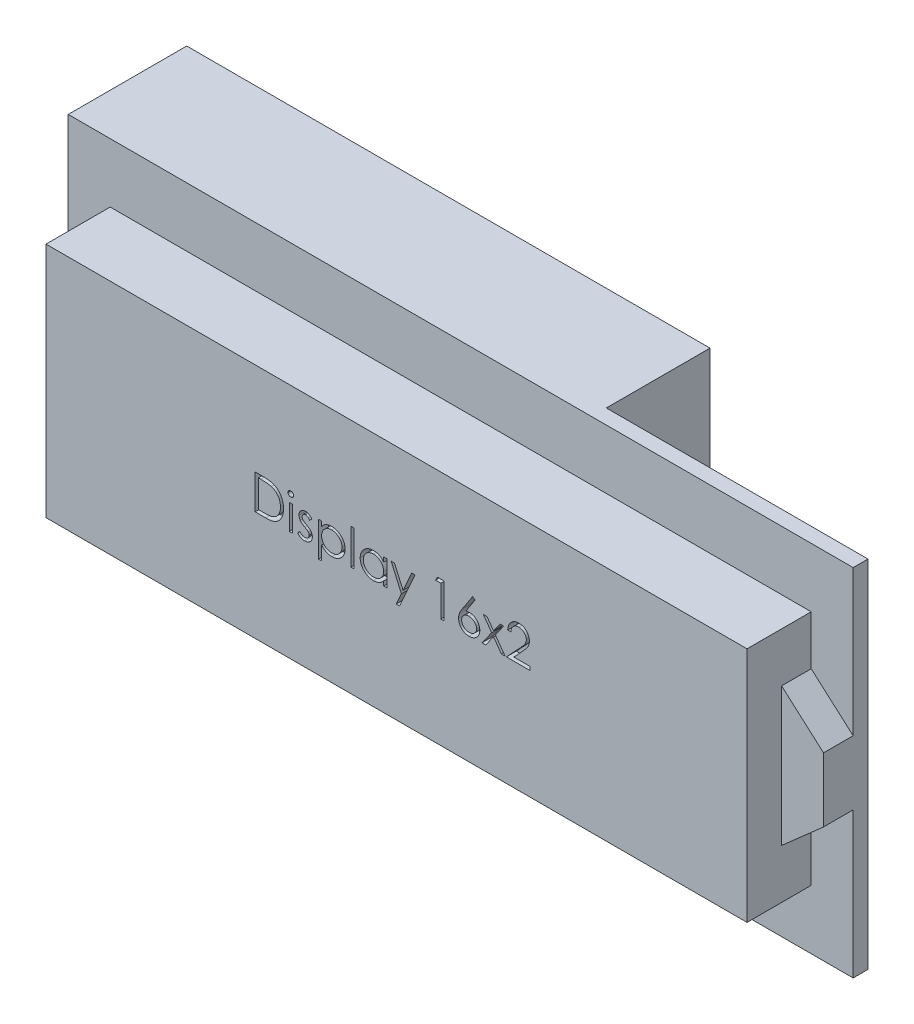
from build123d import *

# Parameters (mm, degrees)
ESBO_O1_W                = 71
ESBO_O1_H                = 24
RESSALTO_EXTRUS_O1_DEPTH = 6.5
ESBO_O2_W                = 79.5
ESBO_O2_H                = 36
RESSALTO_EXTRUS_O2_DEPTH = 1.5
ESBO_O3_W                = 0.314102564
ESBO_O3_H                = 2.557692308
ESBO_O3_H_2              = 3.58974359
CORTE_EXTRUS_O1_DEPTH    = 1
ESBO_O4_W                = 53
ESBO_O4_H                = 18.5
RESSALTO_EXTRUS_O3_DEPTH = 10.5
RESSALTO_EXTRUS_O4_DEPTH = 3


with BuildPart() as part:
    # Esboço1 → Ressalto-extrusão1 (new body)
    with BuildSketch(Plane.XY):
        Rectangle(ESBO_O1_W, ESBO_O1_H)
    extrude(amount=RESSALTO_EXTRUS_O1_DEPTH)

    # Esboço2 → Ressalto-extrusão2 (add)
    with BuildSketch(Plane(origin=(0, 0, 0), x_dir=(-1, 0, 0), z_dir=(0, 0, -1))):
        Rectangle(ESBO_O2_W, ESBO_O2_H)
    extrude(amount=RESSALTO_EXTRUS_O2_DEPTH)

    # Esboço3 → Corte-extrusão1 (cut)
    with BuildSketch(Plane.XY.offset(6.5)):
        with BuildLine():
            Line((-14.316007589, -0.893542468), (-14.316007589, 2.606457532))
            Line((-14.316007589, 2.606457532), (-13.60927682, 2.606457532))
            add(Edge.make_bspline(
                [(-13.60927682, 2.606457532), (-13.547807832, 2.606014962), (-13.429050066, 2.605159919), (-13.257437619, 2.599738528), (-13.098653857, 2.590148062), (-12.953220997, 2.576178536), (-12.820739785, 2.559025503), (-12.701581177, 2.537525098), (-12.595129034, 2.512136928), (-12.529659594, 2.490491478), (-12.498699897, 2.480255609)],
                knots=[0, 0, 0, 0, 1.314313732, 2.53924729, 3.670748893, 4.714932338, 5.66265055, 6.526160246, 7.303039223, 8, 8, 8, 8], degree=3))
            add(Edge.make_bspline(
                [(-12.498699897, 2.480255609), (-12.458205158, 2.464824904), (-12.378133965, 2.434313409), (-12.264126843, 2.376757108), (-12.15680148, 2.311544006), (-12.055582335, 2.238588144), (-11.962781508, 2.155823795), (-11.874773612, 2.06676671), (-11.795158888, 1.968178369), (-11.722250592, 1.862103381), (-11.656514932, 1.749791329), (-11.599375775, 1.63145622), (-11.551921781, 1.507699012), (-11.512528555, 1.378863864), (-11.481482097, 1.244667487), (-11.460300165, 1.104953621), (-11.446329176, 0.960274431), (-11.444925124, 0.862099967), (-11.444212717, 0.812286859)],
                knots=[0, 0, 0, 0, 0.984719456, 1.947108742, 2.898477687, 3.838006223, 4.779231079, 5.722358779, 6.681677486, 7.655904652, 8.64651281, 9.637519902, 10.640069247, 11.656948941, 12.698408672, 13.768548281, 14.867775369, 16, 16, 16, 16], degree=3))
            add(Edge.make_bspline(
                [(-11.444212717, 0.812286859), (-11.444841685, 0.769025621), (-11.446081131, 0.683774832), (-11.457210447, 0.558133936), (-11.473386767, 0.436220365), (-11.498430965, 0.318614665), (-11.528833478, 0.204286447), (-11.567797629, 0.094454203), (-11.612433126, -0.011889607), (-11.664483004, -0.113307083), (-11.721624389, -0.209390455), (-11.782946132, -0.299965983), (-11.848382828, -0.383741205), (-11.918558461, -0.460969817), (-11.992566177, -0.531535395), (-12.070890508, -0.596027411), (-12.153733559, -0.653183966), (-12.240724281, -0.705251074), (-12.33440041, -0.750671429), (-12.436536277, -0.789101439), (-12.547567455, -0.820948054), (-12.667221412, -0.84751895), (-12.795704889, -0.868596253), (-12.933143855, -0.882722645), (-13.079327145, -0.892275578), (-13.17970641, -0.893111971), (-13.231372173, -0.893542468)],
                knots=[0, 0, 0, 0, 1.105936401, 2.179363191, 3.223086493, 4.248585256, 5.251745608, 6.245858792, 7.225916811, 8.198733463, 9.158002045, 10.082870192, 10.993790845, 11.873723703, 12.748670949, 13.606408763, 14.465103618, 15.319838547, 16.196477973, 17.123216899, 18.106603292, 19.147568657, 20.255746949, 21.433717677, 22.679120308, 24, 24, 24, 24], degree=3))
            Line((-13.231372173, -0.893542468), (-14.316007589, -0.893542468))
        make_face()
        with BuildLine():
            Line((-14.001905025, -0.534568109), (-13.600162237, -0.534568109))
            add(Edge.make_bspline(
                [(-13.600162237, -0.534568109), (-13.542433866, -0.534320012), (-13.431401067, -0.533842832), (-13.27174307, -0.529655629), (-13.125863674, -0.522813692), (-12.993742164, -0.513238614), (-12.87545314, -0.500569999), (-12.77074939, -0.486445096), (-12.679974132, -0.468847645), (-12.625044695, -0.452896686), (-12.599661435, -0.445525641)],
                knots=[0, 0, 0, 0, 1.375205317, 2.645023457, 3.804390687, 4.853969522, 5.800190428, 6.637939096, 7.370582563, 8, 8, 8, 8], degree=3))
            add(Edge.make_bspline(
                [(-12.599661435, -0.445525641), (-12.567713073, -0.434274083), (-12.504579435, -0.412039709), (-12.41369835, -0.371482048), (-12.328941345, -0.323439978), (-12.24883132, -0.270037704), (-12.174504665, -0.209391702), (-12.105080548, -0.142820714), (-12.040698747, -0.069985938), (-11.982024439, 0.009022223), (-11.929516135, 0.093712019), (-11.884044905, 0.183250852), (-11.844193374, 0.276657663), (-11.812914781, 0.375366821), (-11.788399197, 0.47849588), (-11.771034509, 0.586052093), (-11.760219785, 0.698015375), (-11.758958337, 0.774167499), (-11.758315282, 0.812987981)],
                knots=[0, 0, 0, 0, 0.998632004, 1.973411704, 2.929992603, 3.868527914, 4.809262121, 5.754881198, 6.702106254, 7.672490631, 8.653608572, 9.636854334, 10.631411391, 11.644891563, 12.686317036, 13.754757253, 14.855430412, 16, 16, 16, 16], degree=3))
            add(Edge.make_bspline(
                [(-11.758315282, 0.812987981), (-11.758828569, 0.853921461), (-11.759836926, 0.934335646), (-11.772511237, 1.052326341), (-11.791032792, 1.165806991), (-11.817816478, 1.274785187), (-11.851947357, 1.379473539), (-11.894541999, 1.479293049), (-11.943208618, 1.575297918), (-12.001111955, 1.665272284), (-12.064527548, 1.750365393), (-12.134905428, 1.828320309), (-12.211127466, 1.899314609), (-12.292362316, 1.964453921), (-12.380899415, 2.021117597), (-12.474653106, 2.071804278), (-12.574998777, 2.11482017), (-12.644811473, 2.137699033), (-12.680290442, 2.149326122)],
                knots=[0, 0, 0, 0, 1.122418816, 2.205001699, 3.251619955, 4.274784885, 5.280384055, 6.268708349, 7.249350384, 8.229342522, 9.199999885, 10.157847722, 11.105861043, 12.055065948, 13.010012805, 13.98527497, 14.976112212, 16, 16, 16, 16], degree=3))
            add(Edge.make_bspline(
                [(-12.680290442, 2.149326122), (-12.709641588, 2.15744255), (-12.772050178, 2.174700302), (-12.873889642, 2.193525675), (-12.988504792, 2.210130174), (-13.116404493, 2.224188213), (-13.257442952, 2.234275535), (-13.41172864, 2.241846849), (-13.579328245, 2.246953482), (-13.695510778, 2.247302189), (-13.755811275, 2.247483173)],
                knots=[0, 0, 0, 0, 0.674548936, 1.434276114, 2.292660221, 3.240891867, 4.284742987, 5.42552168, 6.663806718, 8, 8, 8, 8], degree=3))
            Line((-13.755811275, 2.247483173), (-14.001905025, 2.247483173))
            Line((-14.001905025, 2.247483173), (-14.001905025, -0.534568109))
        make_face(mode=Mode.SUBTRACT)
        with BuildLine():
            add(Edge.make_bspline(
                [(-10.705230346, 2.741072917), (-10.68573903, 2.740168765), (-10.64757129, 2.73839826), (-10.592378022, 2.723236783), (-10.54212101, 2.697537098), (-10.497543277, 2.663057417), (-10.459291391, 2.622507974), (-10.43251068, 2.575247005), (-10.415298284, 2.524188366), (-10.413219729, 2.488573277), (-10.412161435, 2.470439904)],
                knots=[0, 0, 0, 0, 1.055194115, 2.066272739, 3.074728998, 4.095836921, 5.109056067, 6.073838105, 7.019297344, 8, 8, 8, 8], degree=3))
            add(Edge.make_bspline(
                [(-10.412161435, 2.470439904), (-10.413243595, 2.452777251), (-10.415382897, 2.417860276), (-10.432497385, 2.367686804), (-10.459519623, 2.32108252), (-10.497518749, 2.28061181), (-10.54212751, 2.24615119), (-10.592376296, 2.220446451), (-10.647571744, 2.205286314), (-10.685739183, 2.203515625), (-10.705230346, 2.202611378)],
                knots=[0, 0, 0, 0, 0.96129708, 1.900370562, 2.859976407, 3.87933698, 4.906634145, 5.921202961, 6.938410037, 8, 8, 8, 8], degree=3))
            add(Edge.make_bspline(
                [(-10.705230346, 2.202611378), (-10.724498621, 2.203481099), (-10.762001801, 2.205173895), (-10.816368643, 2.220743913), (-10.866197133, 2.246159986), (-10.910861805, 2.280386171), (-10.948091998, 2.321331069), (-10.975190324, 2.367658362), (-10.992265286, 2.417867517), (-10.994409914, 2.452779683), (-10.995494769, 2.470439904)],
                knots=[0, 0, 0, 0, 1.054934014, 2.053291228, 3.073705704, 4.106921865, 5.123545215, 6.088680038, 7.033164197, 8, 8, 8, 8], degree=3))
            add(Edge.make_bspline(
                [(-10.995494769, 2.470439904), (-10.994433682, 2.488570754), (-10.992349641, 2.524180886), (-10.975177525, 2.575275919), (-10.948317717, 2.622257421), (-10.910837154, 2.66328292), (-10.866203693, 2.697528355), (-10.816366948, 2.722939337), (-10.762002249, 2.738510676), (-10.724498773, 2.74020329), (-10.705230346, 2.741072917)],
                knots=[0, 0, 0, 0, 0.98631895, 1.937192651, 2.907499808, 3.917963147, 4.944918757, 5.95915025, 6.951458133, 8, 8, 8, 8], degree=3))
        make_face()
        with Locations((-10.703828102, 0.385303686)):
            Rectangle(ESBO_O3_W, ESBO_O3_H)
        with BuildLine():
            Line((-8.572417846, 1.345139423), (-8.785558871, 1.125688302))
            add(Edge.make_bspline(
                [(-8.785558871, 1.125688302), (-8.803949375, 1.147001448), (-8.839404101, 1.188090685), (-8.895635582, 1.243027751), (-8.951659185, 1.28916469), (-9.006707999, 1.328116949), (-9.062166268, 1.357566096), (-9.117383186, 1.379060958), (-9.172415924, 1.392362763), (-9.20920196, 1.394077202), (-9.227265602, 1.394919071)],
                knots=[0, 0, 0, 0, 1.26578478, 2.440284043, 3.530471711, 4.527705817, 5.468200915, 6.346673037, 7.188140097, 8, 8, 8, 8], degree=3))
            add(Edge.make_bspline(
                [(-9.227265602, 1.394919071), (-9.249404992, 1.393844198), (-9.292972178, 1.391729), (-9.355397996, 1.37061557), (-9.413348621, 1.338206831), (-9.463505601, 1.292238248), (-9.505993281, 1.239473979), (-9.537006962, 1.180477654), (-9.555972946, 1.11702961), (-9.558377678, 1.072999752), (-9.559597333, 1.050668269)],
                knots=[0, 0, 0, 0, 0.99966794, 1.967205029, 2.953328237, 3.988086729, 5.028030931, 6.008226631, 6.989793394, 8, 8, 8, 8], degree=3))
            add(Edge.make_bspline(
                [(-9.559597333, 1.050668269), (-9.558486521, 1.030456225), (-9.556268027, 0.990089114), (-9.539021348, 0.930541081), (-9.511555276, 0.872484042), (-9.485885082, 0.836921136), (-9.47265823, 0.818596955)],
                knots=[0, 0, 0, 0, 0.960159726, 1.917612774, 2.927026955, 4, 4, 4, 4], degree=3))
            add(Edge.make_bspline(
                [(-9.47265823, 0.818596955), (-9.464694736, 0.808812371), (-9.447745444, 0.787987116), (-9.415936929, 0.759083263), (-9.379914426, 0.727141012), (-9.336594488, 0.695204175), (-9.28784346, 0.66157245), (-9.232604176, 0.627570317), (-9.172629671, 0.590605892), (-9.129692364, 0.567161456), (-9.107373775, 0.55497516)],
                knots=[0, 0, 0, 0, 0.66740084, 1.420478572, 2.27185888, 3.217733974, 4.268547843, 5.408967954, 6.65319498, 8, 8, 8, 8], degree=3))
            add(Edge.make_bspline(
                [(-9.107373775, 0.55497516), (-9.080160198, 0.539730258), (-9.027592528, 0.510282125), (-8.952899761, 0.464572422), (-8.88511272, 0.419140998), (-8.823657052, 0.374473724), (-8.769715243, 0.329320856), (-8.721650691, 0.285413099), (-8.680662247, 0.241423791), (-8.65770832, 0.210690677), (-8.646736756, 0.196000802)],
                knots=[0, 0, 0, 0, 1.27191281, 2.456916733, 3.569705269, 4.599008579, 5.553216877, 6.436649441, 7.252746552, 8, 8, 8, 8], degree=3))
            add(Edge.make_bspline(
                [(-8.646736756, 0.196000802), (-8.628526228, 0.166334713), (-8.592283899, 0.107293692), (-8.554225633, 0.010075265), (-8.532165358, -0.093035238), (-8.529103138, -0.163567458), (-8.527546051, -0.199431891)],
                knots=[0, 0, 0, 0, 0.995354457, 1.980940102, 2.973342416, 4, 4, 4, 4], degree=3))
            add(Edge.make_bspline(
                [(-8.527546051, -0.199431891), (-8.528265585, -0.224701037), (-8.529683505, -0.27449665), (-8.539541571, -0.34783148), (-8.556496548, -0.417966037), (-8.579590302, -0.485661322), (-8.610774675, -0.549620262), (-8.647322472, -0.611456511), (-8.691197384, -0.669832441), (-8.741288759, -0.724671402), (-8.796134253, -0.774757149), (-8.854640391, -0.818781103), (-8.916879222, -0.85535544), (-8.982406024, -0.885620785), (-9.051369678, -0.909689043), (-9.123780967, -0.926351575), (-9.199409721, -0.936324336), (-9.25083953, -0.937708812), (-9.277045249, -0.938414263)],
                knots=[0, 0, 0, 0, 1.032770009, 2.035186124, 3.017557409, 3.978232242, 4.952395191, 5.920591857, 6.910227898, 7.931268572, 8.952309245, 9.941945286, 10.918353717, 11.897095711, 12.887975737, 13.898235213, 14.929059601, 16, 16, 16, 16], degree=3))
            add(Edge.make_bspline(
                [(-9.277045249, -0.938414263), (-9.312412425, -0.937421562), (-9.382655352, -0.935449955), (-9.486545071, -0.916943894), (-9.58806583, -0.8881485), (-9.68644937, -0.848432566), (-9.779495484, -0.798281853), (-9.864626408, -0.738219459), (-9.942137871, -0.670229462), (-9.986256145, -0.618116551), (-10.008315282, -0.592060096)],
                knots=[0, 0, 0, 0, 1.013940152, 2.01379169, 3.017749504, 4.037548394, 5.051665909, 6.043208538, 7.021604269, 8, 8, 8, 8], degree=3))
            Line((-10.008315282, -0.592060096), (-9.800082108, -0.355080929))
            add(Edge.make_bspline(
                [(-9.800082108, -0.355080929), (-9.780309695, -0.376435694), (-9.741977883, -0.417835134), (-9.680676666, -0.472959474), (-9.618297265, -0.519160746), (-9.555462579, -0.55780416), (-9.491242484, -0.587579563), (-9.42599687, -0.608498157), (-9.359858446, -0.62194235), (-9.31543631, -0.623520632), (-9.293171051, -0.624311698)],
                knots=[0, 0, 0, 0, 1.179806542, 2.287233372, 3.337373186, 4.324005949, 5.273901747, 6.200048787, 7.097828587, 8, 8, 8, 8], degree=3))
            add(Edge.make_bspline(
                [(-9.293171051, -0.624311698), (-9.262853125, -0.622940874), (-9.203616983, -0.620262512), (-9.118773225, -0.59594542), (-9.040434598, -0.557815468), (-8.972411253, -0.50373077), (-8.914509092, -0.440775197), (-8.872580917, -0.369861078), (-8.846304742, -0.293069621), (-8.843218743, -0.239837319), (-8.841648615, -0.212753205)],
                knots=[0, 0, 0, 0, 1.072336372, 2.095165389, 3.102688358, 4.141489647, 5.156069229, 6.117746104, 7.042326257, 8, 8, 8, 8], degree=3))
            add(Edge.make_bspline(
                [(-8.841648615, -0.212753205), (-8.842734909, -0.190443586), (-8.844879652, -0.146396231), (-8.861722924, -0.08264589), (-8.888335776, -0.022176609), (-8.914540425, 0.013213038), (-8.927886596, 0.03123718)],
                knots=[0, 0, 0, 0, 1.013901739, 2.00181326, 2.98231254, 4, 4, 4, 4], degree=3))
            add(Edge.make_bspline(
                [(-8.927886596, 0.03123718), (-8.93590899, 0.040272542), (-8.953384662, 0.059954824), (-8.985439904, 0.088379903), (-9.023821766, 0.119018002), (-9.068961929, 0.151349591), (-9.120951391, 0.184948196), (-9.180000866, 0.219637548), (-9.245301419, 0.257065274), (-9.29147205, 0.28188493), (-9.315606948, 0.294858975)],
                knots=[0, 0, 0, 0, 0.615000592, 1.339693406, 2.178160186, 3.116406724, 4.166410947, 5.330106347, 6.604359322, 8, 8, 8, 8], degree=3))
            add(Edge.make_bspline(
                [(-9.315606948, 0.294858975), (-9.341653588, 0.309398106), (-9.392166336, 0.337594123), (-9.463713627, 0.381510203), (-9.528260981, 0.426177477), (-9.587361555, 0.469090317), (-9.639522561, 0.512511261), (-9.684538509, 0.556488512), (-9.724181725, 0.599248498), (-9.746129137, 0.629545795), (-9.756612557, 0.644017628)],
                knots=[0, 0, 0, 0, 1.262093308, 2.447601706, 3.550203992, 4.582594899, 5.537233252, 6.418365656, 7.244515135, 8, 8, 8, 8], degree=3))
            add(Edge.make_bspline(
                [(-9.756612557, 0.644017628), (-9.774743157, 0.673163243), (-9.811010692, 0.731464659), (-9.846225883, 0.828775135), (-9.870431912, 0.931220193), (-9.872594302, 1.001907047), (-9.873699897, 1.038048077)],
                knots=[0, 0, 0, 0, 0.985009483, 1.970363186, 2.962279964, 4, 4, 4, 4], degree=3))
            add(Edge.make_bspline(
                [(-9.873699897, 1.038048077), (-9.873165702, 1.061673475), (-9.872120206, 1.107911726), (-9.863776154, 1.175850546), (-9.848584443, 1.2403987), (-9.82952952, 1.302525563), (-9.803046516, 1.361027657), (-9.771400611, 1.416685128), (-9.734213186, 1.469421046), (-9.691369895, 1.518424178), (-9.64426325, 1.562933505), (-9.59336848, 1.601732133), (-9.539830223, 1.634838487), (-9.483421804, 1.662603648), (-9.423601331, 1.683605031), (-9.360786944, 1.698062416), (-9.29510579, 1.707717619), (-9.250204664, 1.708580703), (-9.227265602, 1.709021635)],
                knots=[0, 0, 0, 0, 1.087655834, 2.128696564, 3.144119009, 4.137814668, 5.115653402, 6.093965665, 7.082169637, 8.081268856, 9.086088321, 10.061021666, 11.022561449, 11.980240094, 12.950172527, 13.934149372, 14.944599409, 16, 16, 16, 16], degree=3))
            add(Edge.make_bspline(
                [(-9.227265602, 1.709021635), (-9.200073539, 1.707917294), (-9.145179317, 1.705687896), (-9.062824691, 1.687982206), (-8.980591349, 1.658849102), (-8.898267999, 1.618612868), (-8.816457709, 1.566545993), (-8.734440853, 1.503616693), (-8.651232822, 1.430238979), (-8.599276509, 1.374139753), (-8.572417846, 1.345139423)],
                knots=[0, 0, 0, 0, 0.845714091, 1.707292901, 2.609013841, 3.555613372, 4.552488639, 5.621697636, 6.770543573, 8, 8, 8, 8], degree=3))
        make_face()
        with BuildLine():
            Line((-7.899340923, 1.66414984), (-7.585238358, 1.66414984))
            Line((-7.585238358, 1.66414984), (-7.585238358, 1.190892628))
            add(Edge.make_bspline(
                [(-7.585238358, 1.190892628), (-7.551880874, 1.233830362), (-7.48705728, 1.317271255), (-7.375332375, 1.425261384), (-7.257405566, 1.516336687), (-7.130242153, 1.58771922), (-6.995818463, 1.641540032), (-6.854686146, 1.681319482), (-6.705647381, 1.704760957), (-6.603750928, 1.707582618), (-6.551784833, 1.709021635)],
                knots=[0, 0, 0, 0, 1.0828784, 2.104357462, 3.088488658, 4.04616522, 5.001424249, 5.969181776, 6.964304535, 8, 8, 8, 8], degree=3))
            add(Edge.make_bspline(
                [(-6.551784833, 1.709021635), (-6.50639323, 1.707708456), (-6.416674341, 1.705112889), (-6.284611112, 1.687539834), (-6.157435729, 1.657422142), (-6.035867675, 1.614021227), (-5.91860461, 1.560365757), (-5.80738251, 1.492648721), (-5.700468954, 1.41424253), (-5.600552765, 1.324010379), (-5.508231398, 1.226382113), (-5.428385216, 1.121359809), (-5.359513312, 1.012397222), (-5.303843016, 0.89780513), (-5.260234668, 0.7784859), (-5.229219991, 0.653957459), (-5.210762347, 0.524681519), (-5.208285895, 0.436778798), (-5.20703323, 0.392314904)],
                knots=[0, 0, 0, 0, 1.041296284, 2.058176809, 3.050446431, 4.034000596, 5.01514041, 6.003636468, 7.015969324, 8.052561599, 9.08815499, 10.094063707, 11.074456064, 12.040834395, 13.011057502, 13.983766392, 14.980127149, 16, 16, 16, 16], degree=3))
            add(Edge.make_bspline(
                [(-5.20703323, 0.392314904), (-5.208258716, 0.346912596), (-5.21067555, 0.257372691), (-5.229420556, 0.125885594), (-5.25937743, -0.00060178), (-5.302435613, -0.121879044), (-5.358077102, -0.237862695), (-5.425781662, -0.348469091), (-5.505668129, -0.453662794), (-5.596969257, -0.552015694), (-5.696022193, -0.642615007), (-5.801899682, -0.721853077), (-5.912958608, -0.788394452), (-6.028630775, -0.843977412), (-6.149906414, -0.885869596), (-6.276219691, -0.916087396), (-6.407501838, -0.934721892), (-6.49680299, -0.937174034), (-6.541969128, -0.938414263)],
                knots=[0, 0, 0, 0, 1.038740735, 2.04854663, 3.033179607, 4.009277356, 4.987731542, 5.972001279, 6.972200261, 8.005528982, 9.039189865, 10.040446548, 11.026516639, 11.997840187, 12.972163198, 13.956796175, 14.96660207, 16, 16, 16, 16], degree=3))
            add(Edge.make_bspline(
                [(-6.541969128, -0.938414263), (-6.5927967, -0.937119455), (-6.693196056, -0.93456183), (-6.839993726, -0.90864242), (-6.981270578, -0.869905484), (-7.115461403, -0.813206491), (-7.243629215, -0.740950975), (-7.365049021, -0.652840769), (-7.480365774, -0.549060144), (-7.549774531, -0.470328328), (-7.585238358, -0.430100961)],
                knots=[0, 0, 0, 0, 1.014726462, 2.004382257, 2.969841629, 3.936926163, 4.907207904, 5.903978561, 6.929055279, 8, 8, 8, 8], degree=3))
            Line((-7.585238358, -0.430100961), (-7.585238358, -1.83585016))
            Line((-7.585238358, -1.83585016), (-7.899340923, -1.83585016))
            Line((-7.899340923, -1.83585016), (-7.899340923, 1.66414984))
        make_face()
        with BuildLine():
            add(Edge.make_bspline(
                [(-6.55458932, 1.394919071), (-6.590168882, 1.394278813), (-6.66021587, 1.393018309), (-6.762888089, 1.37804436), (-6.861783517, 1.356306619), (-6.955905468, 1.323394719), (-7.046156085, 1.282995906), (-7.13184025, 1.232513895), (-7.212897817, 1.172861889), (-7.289124848, 1.105182545), (-7.357988141, 1.030607857), (-7.418951069, 0.951020048), (-7.470158374, 0.866519908), (-7.512660394, 0.777894545), (-7.545003677, 0.68444926), (-7.567959397, 0.586716248), (-7.58238975, 0.484588535), (-7.584278687, 0.415032529), (-7.585238358, 0.379694712)],
                knots=[0, 0, 0, 0, 1.05670511, 2.080379991, 3.077984906, 4.06214886, 5.038337365, 6.01289324, 7.01187578, 8.025460281, 9.038092164, 10.024533457, 11.000252242, 11.969694649, 12.940728589, 13.933144304, 14.949937299, 16, 16, 16, 16], degree=3))
            add(Edge.make_bspline(
                [(-7.585238358, 0.379694712), (-7.583647502, 0.333306599), (-7.58053088, 0.242428358), (-7.555193513, 0.109644236), (-7.513958248, -0.016007419), (-7.455429535, -0.133468456), (-7.381481961, -0.241451292), (-7.292383804, -0.338141898), (-7.188941253, -0.422932489), (-7.072874061, -0.494353743), (-6.948451931, -0.552341809), (-6.818666019, -0.59385602), (-6.685301138, -0.619428248), (-6.595132818, -0.622675067), (-6.549681467, -0.624311698)],
                knots=[0, 0, 0, 0, 1.03728447, 2.032128127, 3.01272805, 3.987917167, 4.958271349, 5.931593992, 6.91984656, 7.941419022, 8.973179163, 9.983609215, 10.983593296, 12, 12, 12, 12], degree=3))
            add(Edge.make_bspline(
                [(-6.549681467, -0.624311698), (-6.505145699, -0.622755322), (-6.416750206, -0.619666193), (-6.286592085, -0.592928006), (-6.160101447, -0.552082981), (-6.039921274, -0.492523425), (-5.927097786, -0.419533367), (-5.825216233, -0.331973334), (-5.736209319, -0.23048339), (-5.660344964, -0.117474887), (-5.599213479, 0.003700496), (-5.553283239, 0.129081885), (-5.526774666, 0.258227308), (-5.523017877, 0.345225021), (-5.521135794, 0.388809295)],
                knots=[0, 0, 0, 0, 1.00104056, 1.986885549, 2.97790532, 3.984399681, 4.995088187, 5.994304198, 6.996462723, 8.023150851, 9.048424203, 10.043036403, 11.019596776, 12, 12, 12, 12], degree=3))
            add(Edge.make_bspline(
                [(-5.521135794, 0.388809295), (-5.522590528, 0.432664284), (-5.525488662, 0.520032588), (-5.5540357, 0.648795491), (-5.596935677, 0.774683467), (-5.659494729, 0.894204017), (-5.733695999, 1.006978099), (-5.823442996, 1.106531978), (-5.924059192, 1.193702651), (-6.036748356, 1.265718061), (-6.157688782, 1.323003556), (-6.285003698, 1.364887195), (-6.4180473, 1.390060944), (-6.508674954, 1.393285451), (-6.55458932, 1.394919071)],
                knots=[0, 0, 0, 0, 0.983928682, 1.960191568, 2.949917689, 3.96440592, 4.982380491, 5.975291189, 6.965713506, 7.964880129, 8.970154049, 9.96478489, 10.968906225, 12, 12, 12, 12], degree=3))
        make_face(mode=Mode.SUBTRACT)
        with Locations((-4.466648615, 0.901329327)):
            Rectangle(ESBO_O3_W, ESBO_O3_H_2)
        with BuildLine():
            Line((-0.989084512, 1.66414984), (-0.989084512, -0.893542468))
            Line((-0.989084512, -0.893542468), (-1.303187076, -0.893542468))
            Line((-1.303187076, -0.893542468), (-1.303187076, -0.451134615))
            add(Edge.make_bspline(
                [(-1.303187076, -0.451134615), (-1.338605867, -0.491174209), (-1.407726082, -0.56931198), (-1.5231672, -0.671394153), (-1.645535378, -0.755772474), (-1.774236699, -0.82392239), (-1.909154943, -0.875114446), (-2.04999103, -0.911500605), (-2.196802411, -0.934894441), (-2.297054766, -0.937230462), (-2.347858551, -0.938414263)],
                knots=[0, 0, 0, 0, 1.074387032, 2.096679803, 3.090159297, 4.057316773, 5.018401886, 5.985159533, 6.978961417, 8, 8, 8, 8], degree=3))
            add(Edge.make_bspline(
                [(-2.347858551, -0.938414263), (-2.393026505, -0.93718789), (-2.482099709, -0.93476943), (-2.613128787, -0.916007126), (-2.739221036, -0.885876505), (-2.860495609, -0.843975615), (-2.976167754, -0.788394794), (-3.087227851, -0.721853545), (-3.193100543, -0.642612715), (-3.292172082, -0.552024687), (-3.383404082, -0.4536297), (-3.463465355, -0.348684153), (-3.530218435, -0.237641849), (-3.586038515, -0.121908695), (-3.62903486, -0.000593776), (-3.659008494, 0.125883392), (-3.677748941, 0.257373266), (-3.680166401, 0.346912789), (-3.681392205, 0.392314904)],
                knots=[0, 0, 0, 0, 1.033919861, 2.038935746, 3.024066025, 3.998881131, 4.97069526, 5.957263378, 6.95902576, 7.993208707, 9.027059324, 10.027763471, 11.009749337, 11.988697705, 12.965288445, 13.950418724, 14.960734635, 16, 16, 16, 16], degree=3))
            add(Edge.make_bspline(
                [(-3.681392205, 0.392314904), (-3.680139233, 0.436778608), (-3.677662176, 0.524680951), (-3.659208957, 0.653959649), (-3.628177948, 0.77847791), (-3.5846301, 0.897834853), (-3.528788145, 1.012174903), (-3.460860058, 1.121578928), (-3.380840934, 1.226348326), (-3.288588526, 1.324019552), (-3.188653756, 1.414240167), (-3.081745025, 1.492649212), (-2.970521744, 1.560366061), (-2.853258734, 1.614019537), (-2.731691629, 1.657428642), (-2.604738183, 1.68746161), (-2.472926604, 1.705158931), (-2.383436112, 1.707721695), (-2.338042846, 1.709021635)],
                knots=[0, 0, 0, 0, 1.020392517, 2.01726096, 2.990465484, 3.961182959, 4.928053699, 5.906110375, 6.912531644, 7.948652711, 8.985773172, 9.998621852, 10.987621588, 11.969261332, 12.953316658, 13.946091881, 14.958173133, 16, 16, 16, 16], degree=3))
            add(Edge.make_bspline(
                [(-2.338042846, 1.709021635), (-2.285842987, 1.707583883), (-2.183481527, 1.70476452), (-2.033753517, 1.681301793), (-1.892109039, 1.641663326), (-1.757454687, 1.587745828), (-1.630274001, 1.516097099), (-1.511771017, 1.425717138), (-1.400705534, 1.317175951), (-1.336325242, 1.233805506), (-1.303187076, 1.190892628)],
                knots=[0, 0, 0, 0, 1.038897134, 2.037228247, 3.008116434, 3.962042015, 4.918381754, 5.904844433, 6.921570401, 8, 8, 8, 8], degree=3))
            Line((-1.303187076, 1.190892628), (-1.303187076, 1.66414984))
            Line((-1.303187076, 1.66414984), (-0.989084512, 1.66414984))
        make_face()
        with BuildLine():
            add(Edge.make_bspline(
                [(-2.333836115, 1.394919071), (-2.379750453, 1.393285433), (-2.470378053, 1.390060892), (-2.603422055, 1.364887397), (-2.730735469, 1.323002802), (-2.851681543, 1.265720901), (-2.96434976, 1.193692165), (-3.065043431, 1.106570781), (-3.154586132, 1.006733767), (-3.229894396, 0.894631657), (-3.291284893, 0.774453566), (-3.334451925, 0.648829128), (-3.362921172, 0.52002415), (-3.365829693, 0.432661464), (-3.36728964, 0.388809295)],
                knots=[0, 0, 0, 0, 1.031046209, 2.035121221, 3.029706178, 4.034933723, 5.034054252, 6.02443088, 7.017295772, 8.038157696, 9.050218397, 10.03989886, 11.016116709, 12, 12, 12, 12], degree=3))
            add(Edge.make_bspline(
                [(-3.36728964, 0.388809295), (-3.365424747, 0.345219188), (-3.36170227, 0.258209832), (-3.334951576, 0.129229255), (-3.290071702, 0.003575213), (-3.22882964, -0.11768578), (-3.152143015, -0.230269881), (-3.063254362, -0.332010003), (-2.961304081, -0.419499591), (-2.848376574, -0.492737165), (-2.727768604, -0.551899686), (-2.600934672, -0.593065325), (-2.470259034, -0.619643106), (-2.3814067, -0.622747583), (-2.336640602, -0.624311698)],
                knots=[0, 0, 0, 0, 0.979072187, 1.954306742, 2.945804271, 3.96968567, 4.997920485, 5.998718438, 6.996577872, 8.005894225, 9.015743152, 10.005417472, 10.995077863, 12, 12, 12, 12], degree=3))
            add(Edge.make_bspline(
                [(-2.336640602, -0.624311698), (-2.291194099, -0.622651735), (-2.200805513, -0.619350231), (-2.067366805, -0.594068966), (-1.937871842, -0.552300167), (-1.814084614, -0.494401041), (-1.698768483, -0.422643685), (-1.595270605, -0.338636594), (-1.507754637, -0.24093341), (-1.433562027, -0.133556956), (-1.37538661, -0.01584496), (-1.333010551, 0.109489231), (-1.307956645, 0.242449979), (-1.304798916, 0.333313906), (-1.303187076, 0.379694712)],
                knots=[0, 0, 0, 0, 1.01762866, 2.023962475, 3.030623092, 4.058876274, 5.077231937, 6.066672613, 7.034107872, 8.005628644, 8.981990164, 9.965428785, 10.961468474, 12, 12, 12, 12], degree=3))
            add(Edge.make_bspline(
                [(-1.303187076, 0.379694712), (-1.304146733, 0.415032542), (-1.30603564, 0.484588576), (-1.32046621, 0.586716093), (-1.343421136, 0.684449819), (-1.375767306, 0.777892508), (-1.418258591, 0.866527524), (-1.469506356, 0.950991284), (-1.530411806, 1.030844495), (-1.599994502, 1.104987566), (-1.676159705, 1.172614029), (-1.756754245, 1.232978269), (-1.842732992, 1.282567042), (-1.932650029, 1.323608313), (-2.026661364, 1.356267463), (-2.125531984, 1.378055157), (-2.228210971, 1.393015478), (-2.298257026, 1.394277859), (-2.333836115, 1.394919071)],
                knots=[0, 0, 0, 0, 1.050140795, 2.067009409, 3.05949893, 4.030605086, 5.00011959, 5.97591094, 6.962425594, 7.979863591, 8.993523472, 9.986985069, 10.967611495, 11.937549037, 12.921786183, 13.919465291, 14.943216303, 16, 16, 16, 16], degree=3))
        make_face(mode=Mode.SUBTRACT)
        Polygon((-0.540366564, 1.66414984), (-0.201724737, 1.66414984), (0.66416068, -0.294784455), (1.543367411, 1.66414984), (1.88271036, 1.66414984), (0.312197539, -1.83585016), (-0.02714541, -1.83585016), (0.493788084, -0.67549359), align=None)
        Polygon((4.15224161, 2.606457532), (4.799377026, 2.606457532), (4.799377026, -0.893542468), (4.485274462, -0.893542468), (4.485274462, 2.247483173), (3.946812924, 2.247483173), align=None)
        with BuildLine():
            Line((7.716043693, 2.696201122), (7.957930712, 2.506197116))
            Line((7.957930712, 2.506197116), (7.033151065, 1.092034455))
            add(Edge.make_bspline(
                [(7.033151065, 1.092034455), (7.094721342, 1.101848316), (7.214821128, 1.120991361), (7.336387027, 1.124149306), (7.395631033, 1.125688302)],
                knots=[0, 0, 0, 0, 1.025318673, 2, 2, 2, 2], degree=3))
            add(Edge.make_bspline(
                [(7.395631033, 1.125688302), (7.431203529, 1.12473219), (7.501226929, 1.122850112), (7.604033732, 1.108366262), (7.702822668, 1.08554115), (7.79718428, 1.052268894), (7.887457262, 1.009766539), (7.974159658, 0.958827669), (8.055661668, 0.896821989), (8.133012847, 0.827557033), (8.203239944, 0.750840049), (8.265416, 0.669438712), (8.317642792, 0.583437831), (8.360016713, 0.492880965), (8.392921592, 0.397907705), (8.416909237, 0.298639566), (8.43108883, 0.195008094), (8.433014321, 0.124529919), (8.433992411, 0.088729167)],
                knots=[0, 0, 0, 0, 1.04369286, 2.054478336, 3.041073146, 4.015093852, 4.984733326, 5.965804835, 6.960378782, 7.985147595, 9.009457201, 10.008161701, 10.986880575, 11.956520048, 12.937015923, 13.931873656, 14.949455224, 16, 16, 16, 16], degree=3))
            add(Edge.make_bspline(
                [(8.433992411, 0.088729167), (8.432569306, 0.039749463), (8.429768972, -0.056631003), (8.401865176, -0.197007709), (8.358505532, -0.330740225), (8.296528003, -0.455693396), (8.21954562, -0.571695966), (8.125668027, -0.674481431), (8.018224539, -0.766151469), (7.896737741, -0.842808088), (7.765994777, -0.905411139), (7.628642779, -0.950376381), (7.486015633, -0.97805985), (7.389211025, -0.981530453), (7.340242411, -0.983286057)],
                knots=[0, 0, 0, 0, 1.031375318, 2.029502543, 3.004789286, 3.987476834, 4.960371455, 5.9300674, 6.912260825, 7.929083631, 8.949397511, 9.960523116, 10.96833055, 12, 12, 12, 12], degree=3))
            add(Edge.make_bspline(
                [(7.340242411, -0.983286057), (7.29314571, -0.981757852), (7.199855392, -0.978730744), (7.062622598, -0.951764806), (6.930759581, -0.908057703), (6.8051902, -0.847843425), (6.688869587, -0.771785542), (6.58480395, -0.680223262), (6.493512176, -0.575113797), (6.417537555, -0.45647345), (6.357278823, -0.328983493), (6.312088898, -0.196046336), (6.285692655, -0.058146354), (6.282004098, 0.035334785), (6.280146257, 0.082419071)],
                knots=[0, 0, 0, 0, 1.012016664, 2.004627821, 2.994792927, 3.992885782, 4.990978636, 5.973936114, 6.964471063, 7.975201453, 8.993600317, 9.990122807, 10.98767138, 12, 12, 12, 12], degree=3))
            add(Edge.make_bspline(
                [(6.280146257, 0.082419071), (6.281327702, 0.118463654), (6.283739987, 0.192059806), (6.300583377, 0.303523834), (6.327648172, 0.417574916), (6.357958418, 0.514329109), (6.389984028, 0.593590631), (6.416636568, 0.657494122), (6.449810564, 0.723255195), (6.485183945, 0.793128831), (6.525940814, 0.865314264), (6.570256464, 0.941017933), (6.619356114, 1.019035861), (6.653776277, 1.071980056), (6.671372218, 1.099045673)],
                knots=[0, 0, 0, 0, 1.173818275, 2.396712641, 3.66331629, 4.989737886, 5.693666774, 6.447286557, 7.243889047, 8.091586357, 8.998013824, 9.943181721, 10.948533338, 12, 12, 12, 12], degree=3))
            Line((6.671372218, 1.099045673), (7.716043693, 2.696201122))
        make_face()
        with BuildLine():
            add(Edge.make_bspline(
                [(7.329725584, 0.766713943), (7.303063339, 0.765935899), (7.25098423, 0.764416154), (7.174576815, 0.755590902), (7.102263563, 0.738971836), (7.03308643, 0.717805504), (6.968338727, 0.688702444), (6.907549887, 0.653350645), (6.850484835, 0.611729467), (6.797741283, 0.564428556), (6.74992162, 0.512640523), (6.708740489, 0.457171001), (6.673218089, 0.399356798), (6.64433627, 0.338714856), (6.621846195, 0.275268356), (6.605577944, 0.209309107), (6.596524192, 0.140394801), (6.595017961, 0.093662298), (6.594248821, 0.069798878)],
                knots=[0, 0, 0, 0, 1.129588631, 2.206414736, 3.251139165, 4.268635594, 5.265702196, 6.250456724, 7.242448911, 8.251968645, 9.246821453, 10.222880186, 11.173611482, 12.116736599, 13.062300278, 14.020270554, 14.989073742, 16, 16, 16, 16], degree=3))
            add(Edge.make_bspline(
                [(6.594248821, 0.069798878), (6.594875183, 0.046148899), (6.596103384, -0.000225191), (6.607255704, -0.068564371), (6.624290786, -0.134329279), (6.649631182, -0.197180878), (6.67985807, -0.258077196), (6.719763395, -0.314812481), (6.76398018, -0.370832552), (6.816834114, -0.421834023), (6.873557477, -0.469290647), (6.934158679, -0.510770901), (6.997318639, -0.546257074), (7.063890061, -0.574068172), (7.132928445, -0.596892459), (7.205008999, -0.612953938), (7.280181855, -0.622034464), (7.331103793, -0.623542657), (7.357069334, -0.624311698)],
                knots=[0, 0, 0, 0, 0.989467248, 1.94019797, 2.891935182, 3.827694429, 4.772920941, 5.730924762, 6.725747692, 7.756678648, 8.79901574, 9.819492441, 10.826891316, 11.826466727, 12.835195252, 13.867842842, 14.912794438, 16, 16, 16, 16], degree=3))
            add(Edge.make_bspline(
                [(7.357069334, -0.624311698), (7.383034832, -0.623542597), (7.433956687, -0.622034285), (7.509130147, -0.612954616), (7.581208466, -0.596889968), (7.650254974, -0.574077198), (7.716796406, -0.546223589), (7.779901127, -0.510991669), (7.839929221, -0.469035551), (7.89668982, -0.421915123), (7.949323758, -0.370542271), (7.994601037, -0.315312549), (8.033284271, -0.257618653), (8.064718458, -0.197420763), (8.089779749, -0.134291276), (8.106901216, -0.068574552), (8.118030505, -0.000222526), (8.119261871, 0.046149799), (8.119889847, 0.069798878)],
                knots=[0, 0, 0, 0, 1.087397944, 2.132534446, 3.165364764, 4.174271784, 5.174024072, 6.181601208, 7.194203697, 8.236725232, 9.267838612, 10.269026844, 11.221737037, 12.171628256, 13.107553087, 14.05945871, 15.010357665, 16, 16, 16, 16], degree=3))
            add(Edge.make_bspline(
                [(8.119889847, 0.069798878), (8.119339554, 0.093693429), (8.118259508, 0.140590662), (8.106043559, 0.20927828), (8.089101185, 0.275603486), (8.063518154, 0.339149435), (8.03028161, 0.399665363), (7.989798203, 0.457456964), (7.942965632, 0.512967311), (7.888868093, 0.564530119), (7.829977859, 0.611677197), (7.767362273, 0.653296754), (7.7018543, 0.68842173), (7.633520357, 0.717728832), (7.561577475, 0.738878307), (7.487187135, 0.75553155), (7.409397893, 0.764393567), (7.356621284, 0.765930633), (7.329725584, 0.766713943)],
                knots=[0, 0, 0, 0, 0.978206639, 1.919901502, 2.851605144, 3.780102724, 4.718870031, 5.675451981, 6.667674623, 7.690630536, 8.733308323, 9.756129687, 10.767539656, 11.776269907, 12.797430371, 13.836405707, 14.897401972, 16, 16, 16, 16], degree=3))
        make_face(mode=Mode.SUBTRACT)
        Polygon((8.79296677, 1.66414984), (9.166664686, 1.66414984), (9.825018052, 0.741473558), (10.483371417, 1.66414984), (10.857069334, 1.66414984), (10.012217571, 0.479955128), (10.991684718, -0.893542468), (10.617986802, -0.893542468), (9.825018052, 0.217735577), (9.032049302, -0.893542468), (8.658351385, -0.893542468), (9.638519654, 0.479955128), align=None)
        with BuildLine():
            Line((11.575018052, 1.529534455), (11.260915488, 1.529534455))
            add(Edge.make_bspline(
                [(11.260915488, 1.529534455), (11.262962641, 1.571205343), (11.266983195, 1.653045858), (11.285811484, 1.772369764), (11.312752361, 1.886424563), (11.350843815, 1.994294477), (11.398150093, 2.096933284), (11.45488012, 2.1939333), (11.522073971, 2.284924488), (11.598280705, 2.369063332), (11.681049344, 2.446250903), (11.770355283, 2.512906145), (11.864200311, 2.569223817), (11.96229971, 2.616305059), (12.065760273, 2.651644904), (12.173643131, 2.677866544), (12.286422268, 2.69364289), (12.36326229, 2.695338675), (12.40234177, 2.696201122)],
                knots=[0, 0, 0, 0, 1.10065271, 2.161652631, 3.183658789, 4.190468796, 5.17591951, 6.163126047, 7.15150782, 8.156236427, 9.156009102, 10.134482811, 11.092018607, 12.041330605, 13.001268258, 13.972401359, 14.968799086, 16, 16, 16, 16], degree=3))
            add(Edge.make_bspline(
                [(12.40234177, 2.696201122), (12.440719844, 2.695302666), (12.516131389, 2.693537231), (12.626193403, 2.678376201), (12.730970697, 2.65463061), (12.830258464, 2.621315194), (12.923264529, 2.576530766), (13.010687573, 2.522733227), (13.093568384, 2.460513396), (13.168175167, 2.387259583), (13.236683247, 2.309057198), (13.295785502, 2.225569295), (13.346398665, 2.139340009), (13.388586345, 2.049711807), (13.419642484, 1.955840779), (13.443220692, 1.859093576), (13.456548106, 1.758468765), (13.458593529, 1.690362209), (13.459633436, 1.655736378)],
                knots=[0, 0, 0, 0, 1.111607364, 2.184268762, 3.212621178, 4.221274766, 5.211760367, 6.196651075, 7.1921475, 8.207485113, 9.220403448, 10.201281604, 11.166441695, 12.114753415, 13.065576456, 14.026450734, 14.996634279, 16, 16, 16, 16], degree=3))
            add(Edge.make_bspline(
                [(13.459633436, 1.655736378), (13.457940174, 1.606988544), (13.454583362, 1.51034833), (13.425868986, 1.368333467), (13.381022475, 1.230740048), (13.327025118, 1.120002746), (13.272552674, 1.030769253), (13.223465166, 0.957300548), (13.166000355, 0.878195079), (13.099321857, 0.793717742), (13.024808985, 0.703206837), (12.941786822, 0.606717041), (12.84966334, 0.505245272), (12.785004839, 0.43593967), (12.751500424, 0.400027244)],
                knots=[0, 0, 0, 0, 1.184426356, 2.348067706, 3.509069118, 4.696110526, 5.333549288, 6.050745305, 6.844228056, 7.710549037, 8.667450064, 9.695053472, 10.805634456, 12, 12, 12, 12], degree=3))
            Line((12.751500424, 0.400027244), (11.875799302, -0.534568109))
            Line((11.875799302, -0.534568109), (13.504505231, -0.534568109))
            Line((13.504505231, -0.534568109), (13.504505231, -0.893542468))
            Line((13.504505231, -0.893542468), (11.126300103, -0.893542468))
            Line((11.126300103, -0.893542468), (12.483671898, 0.55497516))
            add(Edge.make_bspline(
                [(12.483671898, 0.55497516), (12.516719785, 0.589473467), (12.580198012, 0.655737654), (12.669980589, 0.752480614), (12.750619577, 0.842230155), (12.82263697, 0.924816703), (12.884470475, 1.001448271), (12.939342707, 1.069642974), (12.983308298, 1.132397425), (13.031023694, 1.205138039), (13.077237675, 1.293950356), (13.116950031, 1.402484045), (13.14116488, 1.514211298), (13.144069715, 1.589713335), (13.145530872, 1.627691507)],
                knots=[0, 0, 0, 0, 1.329631726, 2.553950428, 3.673215718, 4.687767853, 5.603093632, 6.413772471, 7.123043292, 7.734684054, 8.834405432, 9.900288307, 10.943827018, 12, 12, 12, 12], degree=3))
            add(Edge.make_bspline(
                [(13.145530872, 1.627691507), (13.14489513, 1.651572905), (13.143642204, 1.698638555), (13.132584507, 1.767644314), (13.115874, 1.834209128), (13.091928742, 1.898537747), (13.060322002, 1.959983399), (13.021848622, 2.01862088), (12.977458559, 2.075309845), (12.92610729, 2.128463143), (12.86969577, 2.177144348), (12.81010152, 2.220268434), (12.747051416, 2.256307545), (12.680811294, 2.285851042), (12.611565824, 2.309026423), (12.539181079, 2.325085002), (12.463857063, 2.335167486), (12.412423567, 2.336531658), (12.386215968, 2.337226763)],
                knots=[0, 0, 0, 0, 0.991446411, 1.95395049, 2.89581595, 3.838931463, 4.798493298, 5.75982156, 6.748411868, 7.785213223, 8.824556874, 9.840280684, 10.836137867, 11.835679398, 12.848801643, 13.863922112, 14.911575587, 16, 16, 16, 16], degree=3))
            add(Edge.make_bspline(
                [(12.386215968, 2.337226763), (12.358845136, 2.336511731), (12.30509334, 2.335107525), (12.226174307, 2.325284861), (12.150888529, 2.308339021), (12.079046626, 2.285162347), (12.01052704, 2.255703798), (11.945662996, 2.219012053), (11.884600107, 2.17522856), (11.827223584, 2.125588004), (11.774359605, 2.070320403), (11.727912729, 2.008710439), (11.687328715, 1.941883024), (11.651919481, 1.870018474), (11.623163791, 1.792464694), (11.601190641, 1.709496989), (11.583803794, 1.621475607), (11.577995273, 1.560690522), (11.575018052, 1.529534455)],
                knots=[0, 0, 0, 0, 1.031018746, 2.02475058, 2.990194455, 3.934040569, 4.864654155, 5.795059489, 6.735614925, 7.690564532, 8.649604399, 9.611025574, 10.590972636, 11.591080095, 12.624614302, 13.701020113, 14.821632451, 16, 16, 16, 16], degree=3))
        make_face()
    extrude(amount=-CORTE_EXTRUS_O1_DEPTH, mode=Mode.SUBTRACT)

    # Esboço4 → Ressalto-extrusão3 (add)
    with BuildSketch(Plane(origin=(0, 0, -1.5), x_dir=(-1, 0, 0), z_dir=(0, 0, -1))):
        with Locations((13.25, 8.75)):
            Rectangle(ESBO_O4_W, ESBO_O4_H)
    extrude(amount=RESSALTO_EXTRUS_O3_DEPTH)

    # Esboço5 → Ressalto-extrusão4 (add)
    with BuildSketch(Plane.XY):
        Polygon((35.5, 7), (35.5, -7), (39.75, -3.25), (39.75, 3.25), align=None)
    extrude(amount=RESSALTO_EXTRUS_O4_DEPTH)


solid = part.part
